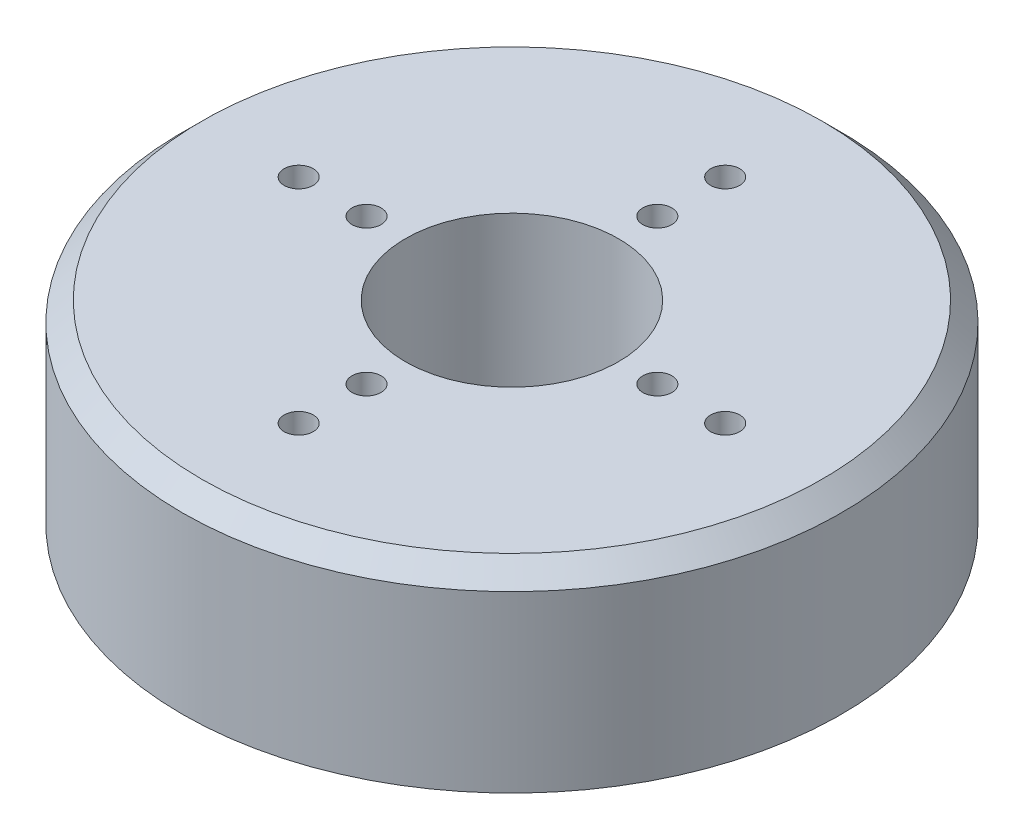
from build123d import *

# Parameters (mm, degrees)
SKETCH_1_R          = 34
SKETCH_1_R_2        = 30
EXTRUDE_1_DEPTH     = 20
EXTRUDE_START       = 20
SKETCH_1_2_R        = 34
SKETCH_1_2_R_2      = 30
EXTRUDE_2_DEPTH     = 4
SKETCH_2_R          = 11
SKETCH_2_R_2        = 1.5
CUT_EXTRUDE_1_DEPTH = 53.076866265
CHAMFER_1_SIZE      = 2
SKETCH_3_R          = 12.5
SKETCH_3_R_2        = 11
EXTRUDE_3_DEPTH     = 16
EXTRUDE_START_2     = 16
SKETCH_3_2_R        = 12.5
SKETCH_3_2_R_2      = 11
EXTRUDE_4_DEPTH     = 3
SKETCH_5_R          = 2.5
CUT_EXTRUDE_2_DEPTH = 52
EXTRUDE_START_3     = 3
SKETCH_6_R          = 30
SKETCH_6_R_2        = 12.5
EXTRUDE_5_DEPTH     = 3


with BuildPart() as part:
    # 草图1 → 凸台-拉伸1 (new body)
    with BuildSketch(Plane(origin=(0, 0, 0), x_dir=(1, 0, 0), z_dir=(0, 1, 0))):
        with Locations(Location((0, 0, 0), (0, 0, 270))):
            Circle(SKETCH_1_R)
        with Locations(Location((0, 0, 0), (0, 0, 270))):
            Circle(SKETCH_1_R_2, mode=Mode.SUBTRACT)
    extrude(amount=EXTRUDE_1_DEPTH)

    # 草图1<2> → 凸台-拉伸2 (add)
    with BuildSketch(Plane(origin=(0, 0, 0), x_dir=(1, 0, 0), z_dir=(0, 1, 0)).offset(EXTRUDE_START)):
        with Locations(Location((0, 0, 0), (0, 0, 270))):
            Circle(SKETCH_1_2_R)
        with Locations(Location((0, 0, 0), (0, 0, 270))):
            Circle(SKETCH_1_2_R_2, mode=Mode.SUBTRACT)
        with Locations(Location((0, 0, 0), (0, 0, 270))):
            Circle(SKETCH_1_2_R_2)
    extrude(amount=-EXTRUDE_2_DEPTH)

    # 草图2 → 切除-拉伸1 (cut, through all)
    with BuildSketch(Plane(origin=(0, 20, 0), x_dir=(1, 0, 0), z_dir=(0, 1, 0))):
        with Locations(Location((0, 0, 0), (0, 0, 270))):
            Circle(SKETCH_2_R)
        with Locations(Location((0, 15, 0), (0, 0, 270))):
            Circle(SKETCH_2_R_2)
        with Locations(Location((0, 22, 0), (0, 0, 270))):
            Circle(SKETCH_2_R_2)
        with Locations(Location((15, 0, 0), (0, 0, 270))):
            Circle(SKETCH_2_R_2)
        with Locations(Location((22, 0, 0), (0, 0, 270))):
            Circle(SKETCH_2_R_2)
        with Locations(Location((0, -15, 0), (0, 0, 270))):
            Circle(SKETCH_2_R_2)
        with Locations(Location((0, -22, 0), (0, 0, 270))):
            Circle(SKETCH_2_R_2)
        with Locations(Location((-15, 0, 0), (0, 0, 270))):
            Circle(SKETCH_2_R_2)
        with Locations(Location((-22, 0, 0), (0, 0, 270))):
            Circle(SKETCH_2_R_2)
    extrude(amount=-CUT_EXTRUDE_1_DEPTH, mode=Mode.SUBTRACT)

    # 倒角1
    chamfer_1_edges = [part.edges().sort_by_distance(p)[0] for p in [
        (0, 20, -34),
    ]]
    chamfer(chamfer_1_edges, length=CHAMFER_1_SIZE)

    # 草图3 → 凸台-拉伸3 (add)
    with BuildSketch(Plane.XZ.offset(-16)):
        with Locations(Location((0, 0, 0), (0, 0, 90))):
            Circle(SKETCH_3_R)
        with Locations(Location((0, 0, 0), (0, 0, 90))):
            Circle(SKETCH_3_R_2, mode=Mode.SUBTRACT)
    extrude(amount=EXTRUDE_3_DEPTH)

    # 草图3<2> → 凸台-拉伸4 (add)
    with BuildSketch(Plane.XZ.offset(-16).offset(EXTRUDE_START_2)):
        with Locations(Location((0, 0, 0), (0, 0, 90))):
            Circle(SKETCH_3_2_R)
        with Locations(Location((0, 0, 0), (0, 0, 90))):
            Circle(SKETCH_3_2_R_2, mode=Mode.SUBTRACT)
        with Locations(Location((0, 0, 0), (0, 0, 90))):
            Circle(SKETCH_3_2_R_2)
    extrude(amount=-EXTRUDE_4_DEPTH)

    # 草图5 → 切除-拉伸2 (cut, through all)
    with BuildSketch(Plane(origin=(0, 3, 0), x_dir=(1, 0, 0), z_dir=(0, 1, 0))):
        with Locations(Location((0, 0, 0), (0, 0, 270))):
            Circle(SKETCH_5_R)
    extrude(amount=-CUT_EXTRUDE_2_DEPTH, mode=Mode.SUBTRACT)

    # 草图6 → 凸台-拉伸5 (add)
    with BuildSketch(Plane.XZ.offset(-16).offset(EXTRUDE_START_3)):
        with Locations(Location((0, 0, 0), (0, 0, 270))):
            Circle(SKETCH_6_R)
        with Locations(Location((0, 0, 0), (0, 0, 90))):
            Circle(SKETCH_6_R_2, mode=Mode.SUBTRACT)
    extrude(amount=EXTRUDE_5_DEPTH)


solid = part.part
